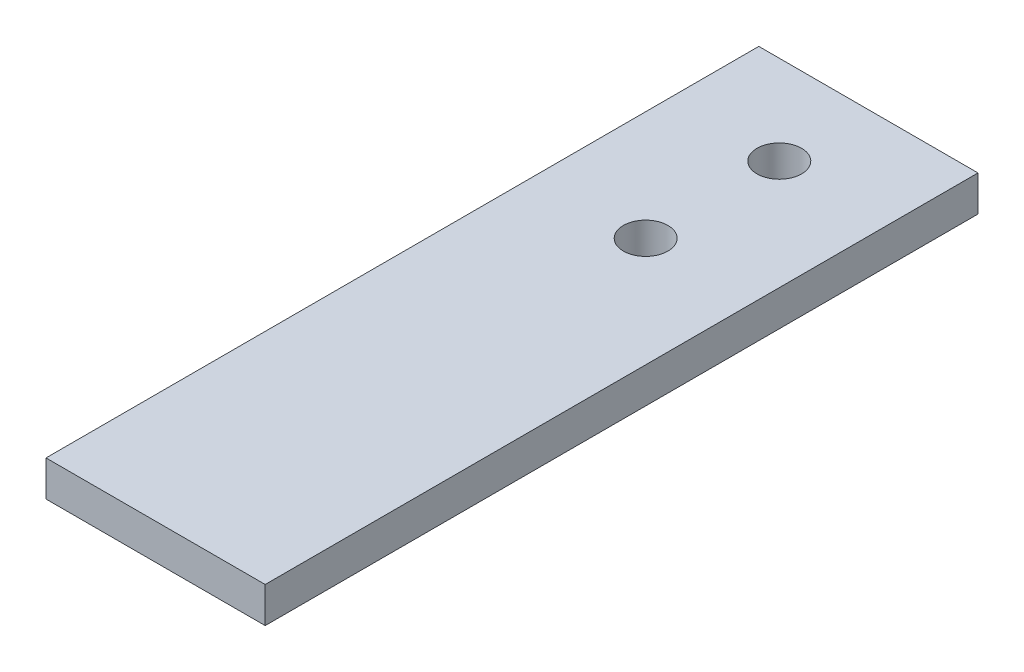
from build123d import *

# Parameters (mm, degrees)
SKETCH1_W                   = 31.242
SKETCH1_H                   = 101.6
BOSS_EXTRUDE1_DEPTH         = 5.08
F_1_4_0_25_DIAMETER_HOLE1_D = 6.35


with BuildPart() as part:
    # Sketch1 → Boss-Extrude1 (new body)
    with BuildSketch(Plane(origin=(0, 0, 0), x_dir=(1, 0, 0), z_dir=(0, 1, 0))):
        with Locations((15.621, 50.8)):
            Rectangle(SKETCH1_W, SKETCH1_H)
    extrude(amount=BOSS_EXTRUDE1_DEPTH)

    # 1/4 (0.25) Diameter Hole1 (through all)
    with Locations(Plane(origin=(0, 0, 0), x_dir=(-1, 0, 0), z_dir=(0, -1, 0))):
        with Locations((-15.621, 69.85), (-15.621, 88.9)):
            Hole(F_1_4_0_25_DIAMETER_HOLE1_D / 2)


solid = part.part
